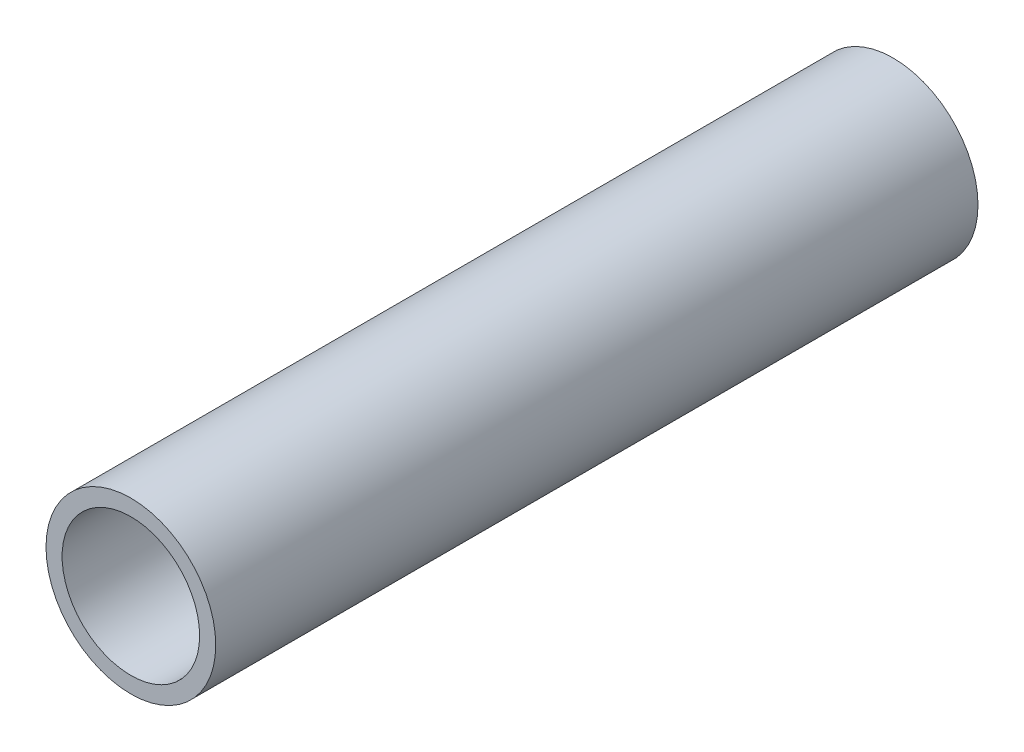
from build123d import *

# Parameters (mm, degrees)
SKETCH1_R           = 16.7
SKETCH1_R_2         = 13.53
BOSS_EXTRUDE1_DEPTH = 150


with BuildPart() as part:
    # Sketch1 → Boss-Extrude1 (new body)
    with BuildSketch(Plane.XY):
        Circle(SKETCH1_R)
        Circle(SKETCH1_R_2, mode=Mode.SUBTRACT)
    extrude(amount=BOSS_EXTRUDE1_DEPTH)


solid = part.part
